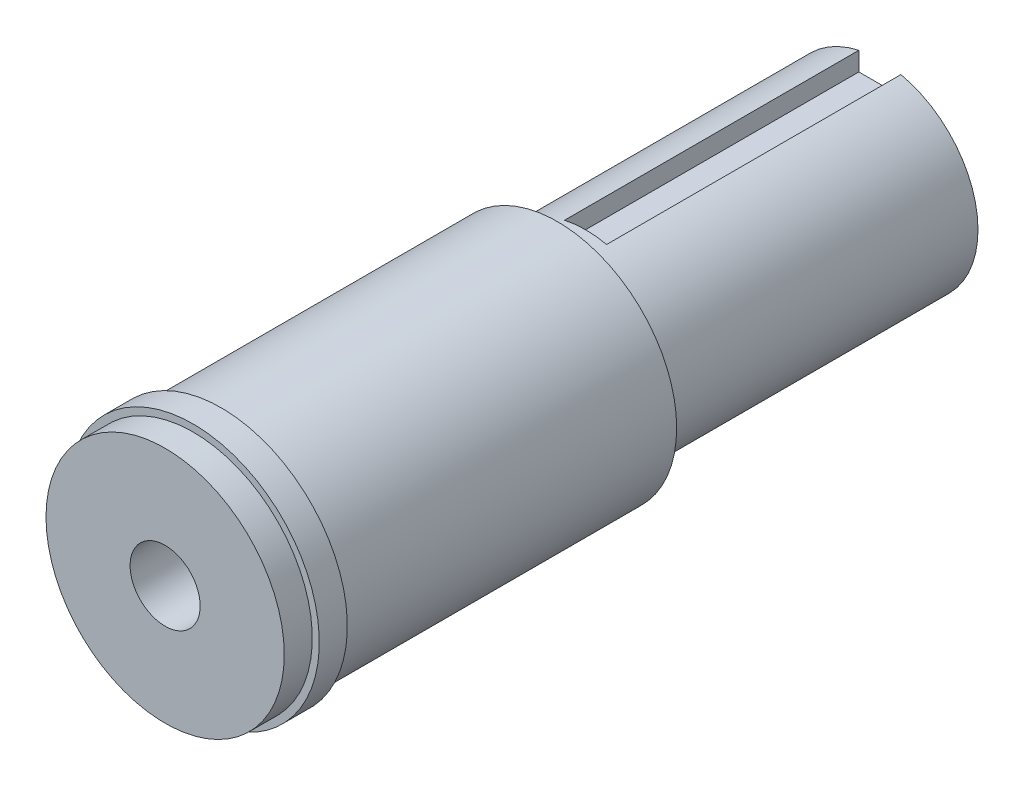
from build123d import *

# Parameters (mm, degrees)
SKETCH1_R                 = 7
BOSS_EXTRUDE1_DEPTH       = 23
SKETCH3_W                 = 3
SKETCH3_H                 = 3
CUT_EXTRUDE1_DEPTH        = 21
SKETCH6_R                 = 8.5
BOSS_EXTRUDE2_DEPTH       = 28
SKETCH7_R                 = 9
BOSS_EXTRUDE3_DEPTH       = 2
M6X1_0_TAPPED_HOLE1_D     = 5
M6X1_0_TAPPED_HOLE1_DEPTH = 20
M6X1_0_TAPPED_HOLE1_TIP   = 1.502151548


with BuildPart() as part:
    # Sketch1 → Boss-Extrude1 (new body)
    with BuildSketch(Plane.XY):
        Circle(SKETCH1_R)
    extrude(amount=BOSS_EXTRUDE1_DEPTH)

    # Sketch3 → Cut-Extrude1 (cut)
    with BuildSketch(Plane(origin=(0, 0, 0), x_dir=(-1, 0, 0), z_dir=(0, 0, -1))):
        with Locations((0, 7)):
            Rectangle(SKETCH3_W, SKETCH3_H)
    extrude(amount=-CUT_EXTRUDE1_DEPTH, mode=Mode.SUBTRACT)

    # Sketch6 → Boss-Extrude2 (add)
    with BuildSketch(Plane.XY.offset(23)):
        Circle(SKETCH6_R)
    extrude(amount=BOSS_EXTRUDE2_DEPTH)

    # Sketch7 → Boss-Extrude3 (add)
    with BuildSketch(Plane(origin=(0, 0, 47), x_dir=(-1, 0, 0), z_dir=(0, 0, -1))):
        Circle(SKETCH7_R)
    extrude(amount=-BOSS_EXTRUDE3_DEPTH)

    # M6x1.0 Tapped Hole1
    with Locations(Plane.XY.offset(51)):
        with Locations((0, 0)):
            Hole(M6X1_0_TAPPED_HOLE1_D / 2, depth=M6X1_0_TAPPED_HOLE1_DEPTH)
            with Locations((0, 0, -(M6X1_0_TAPPED_HOLE1_DEPTH + M6X1_0_TAPPED_HOLE1_TIP / 2))):  # 118° drill point
                Cone(0, M6X1_0_TAPPED_HOLE1_D / 2, M6X1_0_TAPPED_HOLE1_TIP, mode=Mode.SUBTRACT)


solid = part.part
